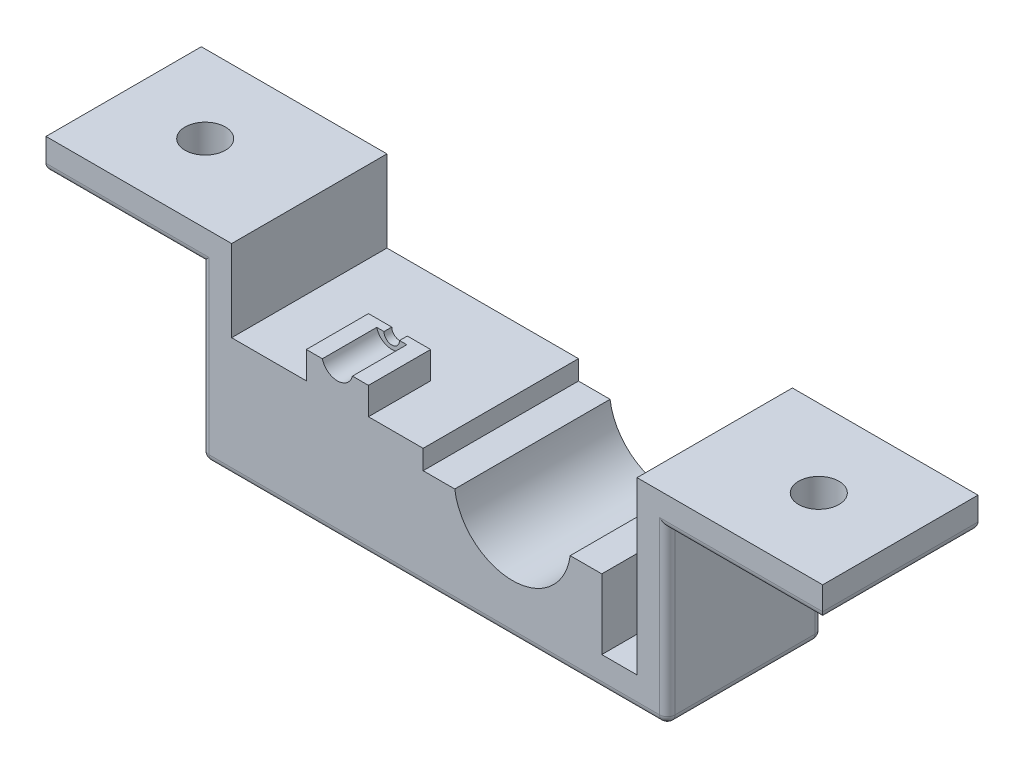
from build123d import *

# Parameters (mm, degrees)
SKETCH_1_W               = 60
SKETCH_1_H               = 26
EXTRUDE_1_DEPTH          = 24
CUT_EXTRUDE_1_DEPTH      = 1
CUT_EXTRUDE_1_DEPTH_BACK = 24
SKETCH_3_W               = 23
SKETCH_3_H               = 24
EXTRUDE_2_DEPTH          = 10
CUT_EXTRUDE_2_DEPTH      = 25
SKETCH_5_W               = 23
SKETCH_5_H               = 1
CUT_EXTRUDE_3_DEPTH      = 25
SKETCH_6_W               = 24.56
SKETCH_6_H               = 24
EXTRUDE_4_DEPTH          = 15.5
CUT_EXTRUDE_5_DEPTH      = 4
CUT_EXTRUDE_6_DEPTH      = 11
SKETCH_10_W              = 8
SKETCH_10_H              = 0.5
CUT_EXTRUDE_8_DEPTH      = 25
SKETCH_11_R              = 1
CUT_EXTRUDE_9_DEPTH      = 11
SKETCH_12_W              = 24
SKETCH_12_H              = 4
EXTRUDE_5_DEPTH          = 20
SKETCH_13_W              = 24
SKETCH_13_H              = 4
EXTRUDE_6_DEPTH          = 20
CUT_EXTRUDE_10_DEPTH     = 4
FILLET_1_R               = 1
SKETCH_15_R              = 2.6
CUT_EXTRUDE_11_DEPTH     = 4
SKETCH_16_R              = 2.6
CUT_EXTRUDE_12_DEPTH     = 4
SKETCH_17_W              = 20
SKETCH_17_H              = 22
CUT_EXTRUDE_13_DEPTH     = 0.1
SKETCH_18_W              = 20
SKETCH_18_H              = 10.5
CUT_EXTRUDE_14_DEPTH     = 0.1


with BuildPart() as part:
    # 草图1 → 凸台-拉伸1 (new body)
    with BuildSketch(Plane.XY):
        with Locations((5.238297872, -1.05106383)):
            Rectangle(SKETCH_1_W, SKETCH_1_H)
    extrude(amount=-EXTRUDE_1_DEPTH)

    # 草图2 → 切除-拉伸1 (cut, two sides)
    with BuildSketch(Plane.XY) as cut_extrude_1_sk:
        Polygon((-20.761702128, 145.431728494), (-20.761702128, 11.94893617), (-20.761702128, -10.05106383), (31.238297872, -10.05106383), (31.238297872, 11.94893617), (31.238297872, 145.431728494), (31.238297872, 412.397313141), (-20.761702128, 412.397313141), align=None)
    extrude(amount=CUT_EXTRUDE_1_DEPTH, mode=Mode.SUBTRACT)
    extrude(cut_extrude_1_sk.sketch, amount=-CUT_EXTRUDE_1_DEPTH_BACK, mode=Mode.SUBTRACT)

    # 草图3 → 凸台-拉伸2 (add)
    with BuildSketch(Plane(origin=(0, -10.05106383, 0), x_dir=(1, 0, 0), z_dir=(0, 1, 0))):
        with Locations((15.298297872, 12)):
            Rectangle(SKETCH_3_W, SKETCH_3_H)
    extrude(amount=EXTRUDE_2_DEPTH)

    # 草图4 → 切除-拉伸2 (cut, through all)
    with BuildSketch(Plane.XY):
        with BuildLine():
            Line((7.798297872, -0.05106383), (22.798297872, -0.05106383))
            ThreePointArc((22.798297872, -0.05106383), (15.298297872, -7.55106383), (7.798297872, -0.05106383))
        make_face()
    extrude(amount=-CUT_EXTRUDE_2_DEPTH, mode=Mode.SUBTRACT)

    # 草图5 → 切除-拉伸3 (cut, through all)
    with BuildSketch(Plane.XY):
        with Locations((15.298297872, -0.55106383)):
            Rectangle(SKETCH_5_W, SKETCH_5_H)
    extrude(amount=-CUT_EXTRUDE_3_DEPTH, mode=Mode.SUBTRACT)

    # 草图6 → 凸台-拉伸4 (add)
    with BuildSketch(Plane(origin=(0, -10.05106383, 0), x_dir=(1, 0, 0), z_dir=(0, 1, 0))):
        with Locations((-8.481702128, 12)):
            Rectangle(SKETCH_6_W, SKETCH_6_H)
    extrude(amount=EXTRUDE_4_DEPTH)

    # 草图7 → 切除-拉伸5 (cut)
    with BuildSketch(Plane(origin=(0, 5.44893617, 0), x_dir=(1, 0, 0), z_dir=(0, 1, 0))):
        Polygon((-20.761702128, 0), (-11.241702128, 0), (-11.241702128, 12), (-3.241702128, 12), (-3.241702128, 0), (3.798297872, 0), (3.798297872, 24), (-20.761702128, 24), align=None)
    extrude(amount=-CUT_EXTRUDE_5_DEPTH, mode=Mode.SUBTRACT)

    # 草图8 → 切除-拉伸6 (cut)
    with BuildSketch(Plane.XY):
        with BuildLine():
            Line((-9.241702128, 5.44893617), (-5.241702128, 5.44893617))
            ThreePointArc((-5.241702128, 5.44893617), (-7.241702128, 3.44893617), (-9.241702128, 5.44893617))
        make_face()
    extrude(amount=-CUT_EXTRUDE_6_DEPTH, mode=Mode.SUBTRACT)

    # 草图10 → 切除-拉伸8 (cut, through all)
    with BuildSketch(Plane.XY):
        with Locations((-7.241702128, 5.19893617)):
            Rectangle(SKETCH_10_W, SKETCH_10_H)
    extrude(amount=-CUT_EXTRUDE_8_DEPTH, mode=Mode.SUBTRACT)

    # 草图11 → 切除-拉伸9 (cut)
    with BuildSketch(Plane(origin=(0, 0, -12), x_dir=(-1, 0, 0), z_dir=(0, 0, -1))):
        with Locations((7.241702128, 4.94893617)):
            Circle(SKETCH_11_R)
    extrude(amount=-CUT_EXTRUDE_9_DEPTH, mode=Mode.SUBTRACT)

    # 草图12 → 凸台-拉伸5 (add)
    with BuildSketch(Plane(origin=(35.238297872, 0, 0), x_dir=(0, 0, -1), z_dir=(1, 0, 0))):
        with Locations((12, 9.94893617)):
            Rectangle(SKETCH_12_W, SKETCH_12_H)
    extrude(amount=EXTRUDE_5_DEPTH)

    # 草图13 → 凸台-拉伸6 (add)
    with BuildSketch(Plane.ZY.offset(24.761702128)):
        with Locations((-12, 9.94893617)):
            Rectangle(SKETCH_13_W, SKETCH_13_H)
    extrude(amount=EXTRUDE_6_DEPTH)

    # 草图14 → 切除-拉伸10 (cut)
    with BuildSketch(Plane.XY):
        with BuildLine():
            Line((-9.178193801, 4.94893617), (-11.241702128, 4.94893617))
            Line((-11.241702128, 4.94893617), (-11.241702128, 1.44893617))
            Line((-11.241702128, 1.44893617), (-20.761702128, 1.44893617))
            Line((-20.761702128, 1.44893617), (-20.761702128, 11.94893617))
            Line((-20.761702128, 11.94893617), (-44.761702128, 11.94893617))
            Line((-44.761702128, 11.94893617), (-44.761702128, 7.94893617))
            Line((-44.761702128, 7.94893617), (-24.761702128, 7.94893617))
            Line((-24.761702128, 7.94893617), (-24.761702128, -14.05106383))
            Line((-24.761702128, -14.05106383), (35.238297872, -14.05106383))
            Line((35.238297872, -14.05106383), (35.238297872, 7.94893617))
            Line((35.238297872, 7.94893617), (55.238297872, 7.94893617))
            Line((55.238297872, 7.94893617), (55.238297872, 11.94893617))
            Line((55.238297872, 11.94893617), (31.238297872, 11.94893617))
            Line((31.238297872, 11.94893617), (31.238297872, -10.05106383))
            Line((31.238297872, -10.05106383), (26.798297872, -10.05106383))
            Line((26.798297872, -10.05106383), (26.798297872, -1.05106383))
            Line((26.798297872, -1.05106383), (22.731332246, -1.05106383))
            ThreePointArc((22.731332246, -1.05106383), (15.298297872, -7.55106383), (7.865263499, -1.05106383))
            Line((7.865263499, -1.05106383), (3.798297872, -1.05106383))
            Line((3.798297872, -1.05106383), (3.798297872, 1.44893617))
            Line((3.798297872, 1.44893617), (-3.241702128, 1.44893617))
            Line((-3.241702128, 1.44893617), (-3.241702128, 4.94893617))
            Line((-3.241702128, 4.94893617), (-5.305210455, 4.94893617))
            ThreePointArc((-5.305210455, 4.94893617), (-7.241702128, 3.44893617), (-9.178193801, 4.94893617))
        make_face()
    extrude(amount=-CUT_EXTRUDE_10_DEPTH, mode=Mode.SUBTRACT)

    # 圆角1
    fillet_1_edges = [part.edges().sort_by_distance(p)[0] for p in [
        (35.238297872, -3.05106383, -24),
        (45.238297872, 7.94893617, -24),
        (-24.761702128, -3.05106383, -24),
        (-34.761702128, 7.94893617, -24),
        (-44.761702128, 7.94893617, -14),
        (55.238297872, 7.94893617, -14),
        (45.238297872, 7.94893617, -4),
        (35.238297872, -3.05106383, -4),
        (5.238297872, -14.05106383, -4),
        (-24.761702128, -3.05106383, -4),
        (-34.761702128, 7.94893617, -4),
        (35.238297872, -14.05106383, -14),
        (-24.761702128, -14.05106383, -14),
        (5.238297872, -14.05106383, -24),
    ]]
    fillet(fillet_1_edges, radius=FILLET_1_R)

    # 草图15 → 切除-拉伸11 (cut)
    with BuildSketch(Plane(origin=(0, 7.94893617, 0), x_dir=(-1, 0, 0), z_dir=(0, -1, 0))):
        with Locations((34.261702128, 14)):
            Circle(SKETCH_15_R)
    extrude(amount=-CUT_EXTRUDE_11_DEPTH, mode=Mode.SUBTRACT)

    # 草图16 → 切除-拉伸12 (cut)
    with BuildSketch(Plane(origin=(0, 7.94893617, 0), x_dir=(-1, 0, 0), z_dir=(0, -1, 0))):
        with Locations((-44.738297872, 14)):
            Circle(SKETCH_16_R)
    extrude(amount=-CUT_EXTRUDE_12_DEPTH, mode=Mode.SUBTRACT)

    # 草图17 → 切除-拉伸13 (cut)
    with BuildSketch(Plane.ZY.offset(-31.238297872)):
        with Locations((-14, 0.94893617)):
            Rectangle(SKETCH_17_W, SKETCH_17_H)
    extrude(amount=-CUT_EXTRUDE_13_DEPTH, mode=Mode.SUBTRACT)

    # 草图18 → 切除-拉伸14 (cut)
    with BuildSketch(Plane(origin=(-20.761702128, 0, 0), x_dir=(0, 0, -1), z_dir=(1, 0, 0))):
        with Locations((14, 6.69893617)):
            Rectangle(SKETCH_18_W, SKETCH_18_H)
    extrude(amount=-CUT_EXTRUDE_14_DEPTH, mode=Mode.SUBTRACT)


solid = part.part
